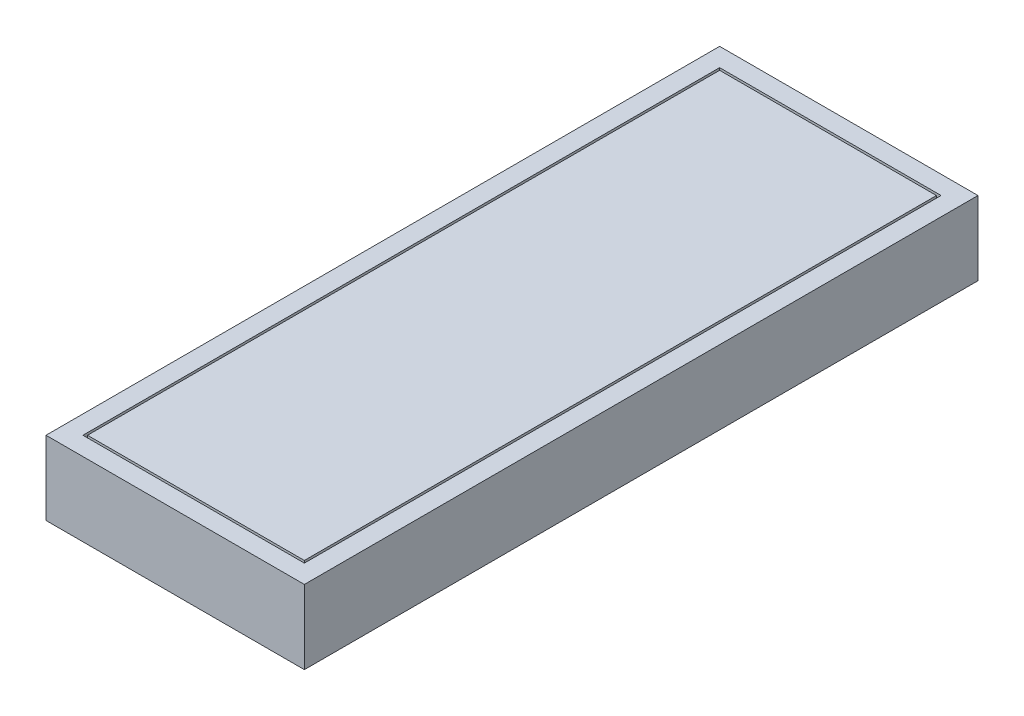
from build123d import *

# Parameters (mm, degrees)
SKETCH1_W           = 280
SKETCH1_H           = 730
BOSS_EXTRUDE1_DEPTH = 80
SKETCH2_W           = 240
SKETCH2_H           = 690
CUT_EXTRUDE1_DEPTH  = 11
SKETCH3_W           = 235
SKETCH3_H           = 685
BOSS_EXTRUDE2_DEPTH = 11


with BuildPart() as part:
    # Sketch1 → Boss-Extrude1 (new body)
    with BuildSketch(Plane.XZ.offset(60)):
        with Locations((0, 365)):
            Rectangle(SKETCH1_W, SKETCH1_H)
    extrude(amount=-BOSS_EXTRUDE1_DEPTH)

    # Sketch2 → Cut-Extrude1 (cut)
    with BuildSketch(Plane(origin=(0, 20, 0), x_dir=(-1, 0, 0), z_dir=(0, 1, 0))):
        with Locations((0, 365)):
            Rectangle(SKETCH2_W, SKETCH2_H)
    extrude(amount=-CUT_EXTRUDE1_DEPTH, mode=Mode.SUBTRACT)

    # Sketch3 → Boss-Extrude2 (add)
    with BuildSketch(Plane(origin=(0, 9, 0), x_dir=(-1, 0, 0), z_dir=(0, 1, 0))):
        with Locations((0, 365)):
            Rectangle(SKETCH3_W, SKETCH3_H)
    extrude(amount=BOSS_EXTRUDE2_DEPTH)


solid = part.part
